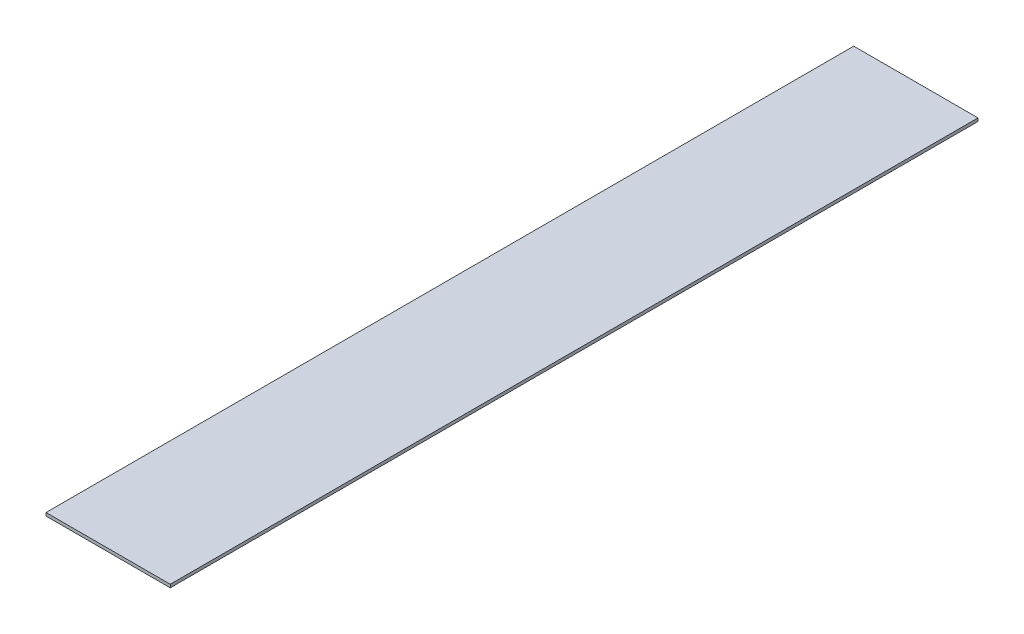
from build123d import *

# Parameters (mm, degrees)
SKETCH1_W           = 50.8
SKETCH1_H           = 330.2
BOSS_EXTRUDE1_DEPTH = 1.27


with BuildPart() as part:
    # Sketch1 → Boss-Extrude1 (new body)
    with BuildSketch(Plane(origin=(0, 0, 0), x_dir=(1, 0, 0), z_dir=(0, 1, 0))):
        Rectangle(SKETCH1_W, SKETCH1_H)
    extrude(amount=BOSS_EXTRUDE1_DEPTH)


solid = part.part
